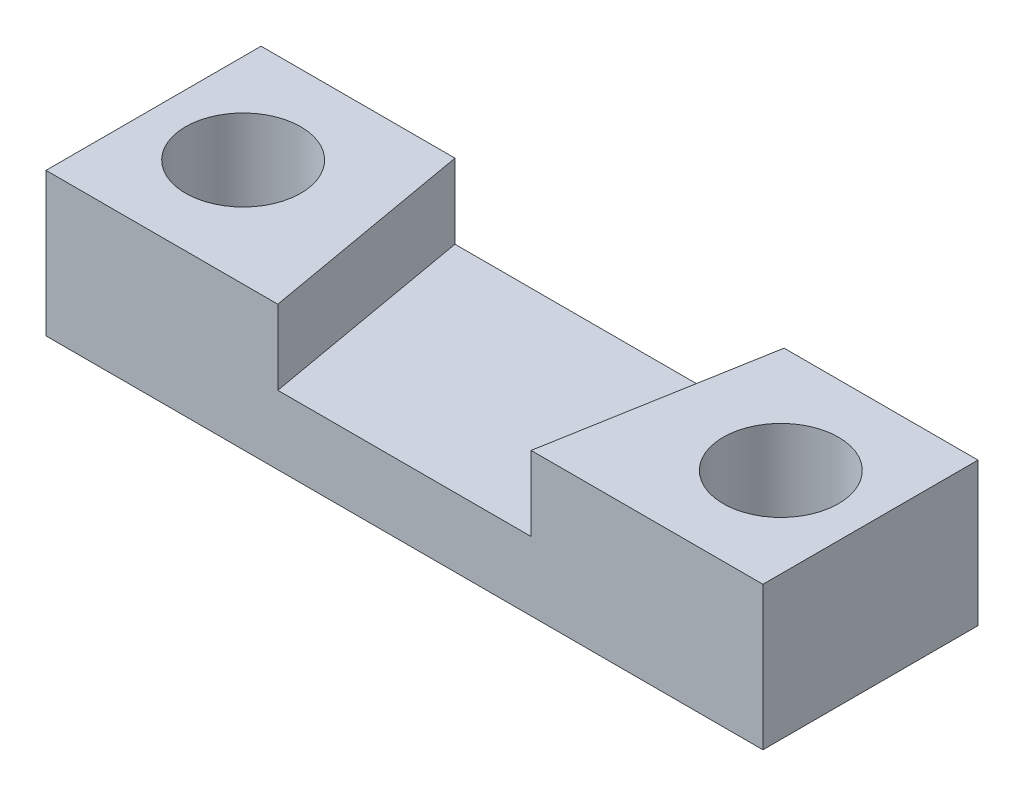
from build123d import *

# Parameters (mm, degrees)
SKETCH1_W                  = 31.75
SKETCH1_H                  = 9.525
BOSS_EXTRUDE1_DEPTH        = 6.35
F_10_CLEARANCE_HOLE1_D     = 5.1054
F_10_CLEARANCE_HOLE1_DEPTH = 19.05
F_10_CLEARANCE_HOLE1_TIP   = 1.533816902
CUT_EXTRUDE1_DEPTH         = 3.302


with BuildPart() as part:
    # Sketch1 → Boss-Extrude1 (new body)
    with BuildSketch(Plane(origin=(0, 0, 0), x_dir=(1, 0, 0), z_dir=(0, 1, 0))):
        Rectangle(SKETCH1_W, SKETCH1_H)
    extrude(amount=BOSS_EXTRUDE1_DEPTH)

    # #10 Clearance Hole1
    with Locations(Plane(origin=(0, 0, 0), x_dir=(-1, 0, 0), z_dir=(0, -1, 0))):
        with Locations((11.90625, 0), (-11.90625, 0)):
            Hole(F_10_CLEARANCE_HOLE1_D / 2, depth=F_10_CLEARANCE_HOLE1_DEPTH)
            with Locations((0, 0, -(F_10_CLEARANCE_HOLE1_DEPTH + F_10_CLEARANCE_HOLE1_TIP / 2))):  # 118° drill point
                Cone(0, F_10_CLEARANCE_HOLE1_D / 2, F_10_CLEARANCE_HOLE1_TIP, mode=Mode.SUBTRACT)

    # Sketch4 → Cut-Extrude1 (cut)
    with BuildSketch(Plane(origin=(0, 6.35, 0), x_dir=(1, 0, 0), z_dir=(0, 1, 0))):
        Polygon((7.287716231, 4.7625), (5.60820174, -4.7625), (-5.60820174, -4.7625), (-7.287716231, 4.7625), align=None)
    extrude(amount=-CUT_EXTRUDE1_DEPTH, mode=Mode.SUBTRACT)


solid = part.part
